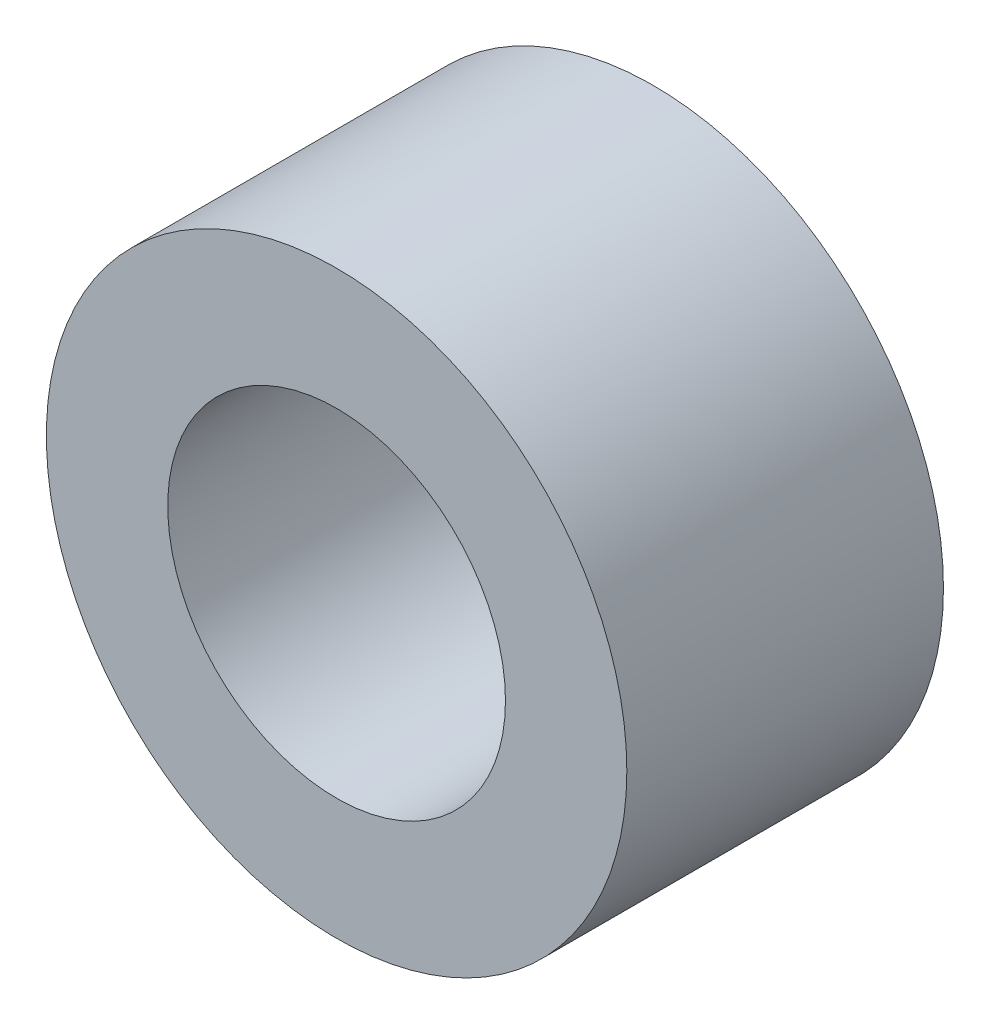
from build123d import *

# Parameters (mm, degrees)
ESQUISSE1_R        = 2.75
ESQUISSE1_R_2      = 1.6
BOSS_EXTRU_1_DEPTH = 3


with BuildPart() as part:
    # Esquisse1 → Boss.-Extru.1 (new body)
    with BuildSketch(Plane.XY):
        Circle(ESQUISSE1_R)
        Circle(ESQUISSE1_R_2, mode=Mode.SUBTRACT)
    extrude(amount=BOSS_EXTRU_1_DEPTH)


solid = part.part
